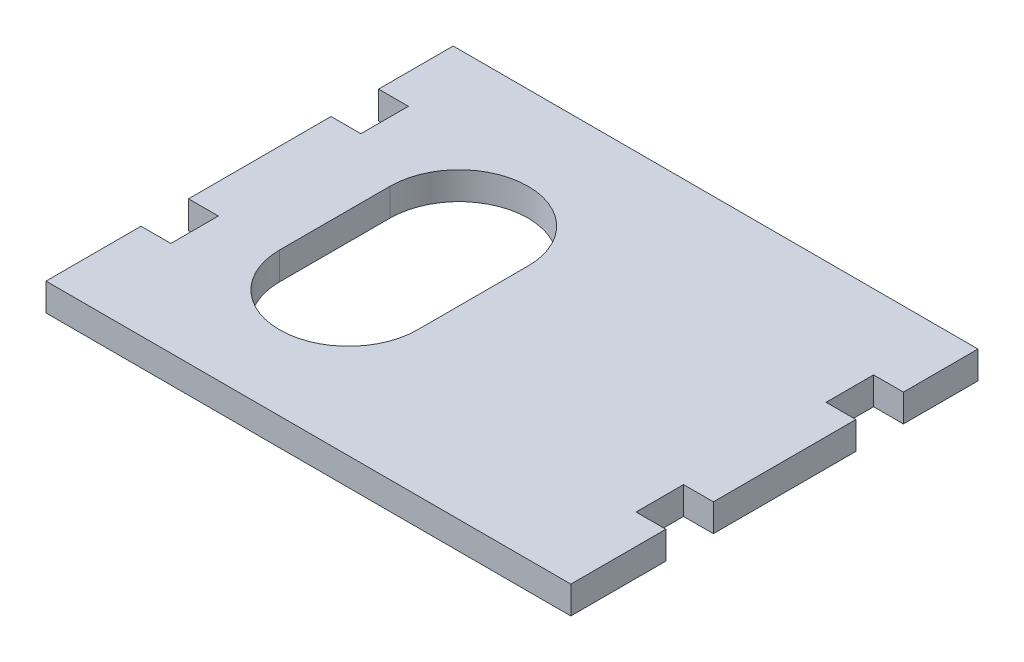
from build123d import *

# Parameters (mm, degrees)
SKETCH1_W           = 95
SKETCH1_H           = 73.7
BOSS_EXTRUDE1_DEPTH = 5
CUT_EXTRUDE1_REACH  = 7
SKETCH2_W           = 5.4
SKETCH2_H           = 8.6
CUT_EXTRUDE2_REACH  = 7


with BuildPart() as part:
    # Sketch1 → Boss-Extrude1 (new body)
    with BuildSketch(Plane(origin=(0, 0, 0), x_dir=(1, 0, 0), z_dir=(0, 1, 0))):
        with Locations((3.050458716, -12.337385321)):
            Rectangle(SKETCH1_W, SKETCH1_H)
    extrude(amount=BOSS_EXTRUDE1_DEPTH)

    # Sketch2 → Cut-Extrude1 (cut, up to next)
    with BuildSketch(Plane(origin=(0, 5, 0), x_dir=(1, 0, 0), z_dir=(0, 1, 0)), mode=Mode.PRIVATE) as cut_extrude1_sk1:
        with Locations((-41.749541284, 6.712614679)):
            Rectangle(SKETCH2_W, SKETCH2_H)
    cut_extrude1_tool1 = extrude(cut_extrude1_sk1.sketch, amount=-CUT_EXTRUDE1_REACH, mode=Mode.PRIVATE) & part.part
    add(cut_extrude1_tool1.solids().sort_by_distance((-41.749541, 5, -6.712615))[0], mode=Mode.SUBTRACT)
    # Sketch2 → Cut-Extrude1 (cut, up to next)
    with BuildSketch(Plane(origin=(0, 5, 0), x_dir=(1, 0, 0), z_dir=(0, 1, 0)), mode=Mode.PRIVATE) as cut_extrude1_sk2:
        with Locations((-41.749541284, -27.687385321)):
            Rectangle(SKETCH2_W, SKETCH2_H)
    cut_extrude1_tool2 = extrude(cut_extrude1_sk2.sketch, amount=-CUT_EXTRUDE1_REACH, mode=Mode.PRIVATE) & part.part
    add(cut_extrude1_tool2.solids().sort_by_distance((-41.749541, 5, 27.687385))[0], mode=Mode.SUBTRACT)
    # Sketch2 → Cut-Extrude1 (cut, up to next)
    with BuildSketch(Plane(origin=(0, 5, 0), x_dir=(1, 0, 0), z_dir=(0, 1, 0)), mode=Mode.PRIVATE) as cut_extrude1_sk3:
        with Locations((47.850458716, 6.712614679)):
            Rectangle(SKETCH2_W, SKETCH2_H)
    cut_extrude1_tool3 = extrude(cut_extrude1_sk3.sketch, amount=-CUT_EXTRUDE1_REACH, mode=Mode.PRIVATE) & part.part
    add(cut_extrude1_tool3.solids().sort_by_distance((47.850459, 5, -6.712615))[0], mode=Mode.SUBTRACT)
    # Sketch2 → Cut-Extrude1 (cut, up to next)
    with BuildSketch(Plane(origin=(0, 5, 0), x_dir=(1, 0, 0), z_dir=(0, 1, 0)), mode=Mode.PRIVATE) as cut_extrude1_sk4:
        with Locations((47.850458716, -27.687385321)):
            Rectangle(SKETCH2_W, SKETCH2_H)
    cut_extrude1_tool4 = extrude(cut_extrude1_sk4.sketch, amount=-CUT_EXTRUDE1_REACH, mode=Mode.PRIVATE) & part.part
    add(cut_extrude1_tool4.solids().sort_by_distance((47.850459, 5, 27.687385))[0], mode=Mode.SUBTRACT)

    # Sketch3 → Cut-Extrude2 (cut, up to next)
    with BuildSketch(Plane(origin=(0, 5, 0), x_dir=(1, 0, 0), z_dir=(0, 1, 0)), mode=Mode.PRIVATE) as cut_extrude2_sk1:
        with BuildLine():
            Line((-3.185639247, -3.188538713), (-3.185639247, -23.188538713))
            ThreePointArc((-3.185639247, -23.188538713), (-15.685639247, -35.688538713), (-28.185639247, -23.188538713))
            Line((-28.185639247, -23.188538713), (-28.185639247, -3.188538713))
            ThreePointArc((-28.185639247, -3.188538713), (-15.685639247, 9.311461287), (-3.185639247, -3.188538713))
        make_face()
    cut_extrude2_tool1 = extrude(cut_extrude2_sk1.sketch, amount=-CUT_EXTRUDE2_REACH, mode=Mode.PRIVATE) & part.part
    add(cut_extrude2_tool1.solids().sort_by_distance((-15.685639, 5, 13.188539))[0], mode=Mode.SUBTRACT)


solid = part.part
